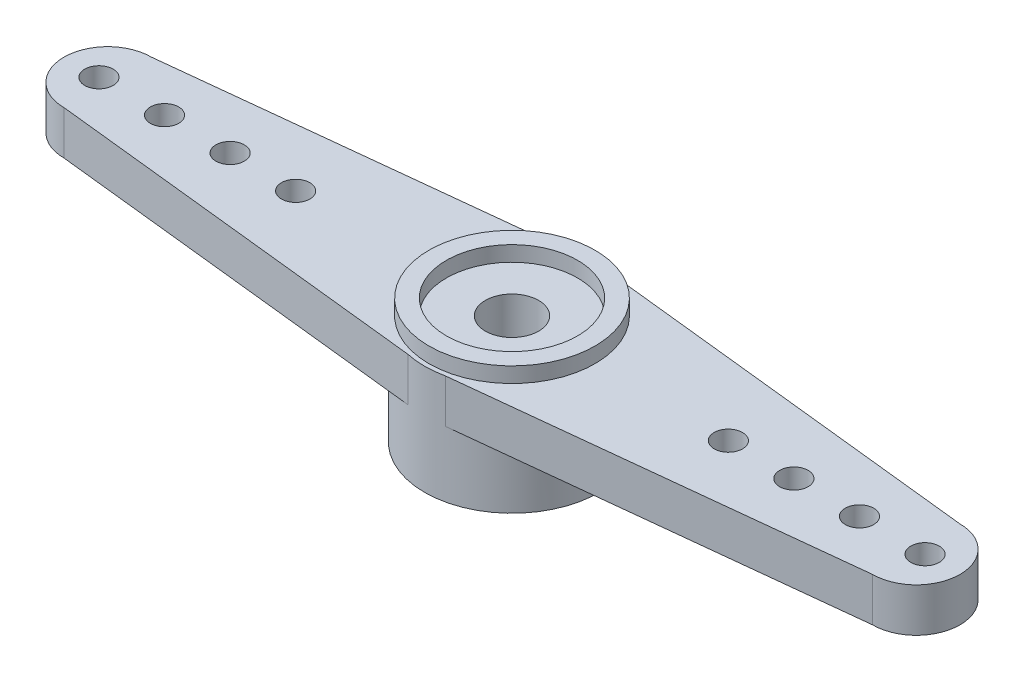
from build123d import *

# Parameters (mm, degrees)
SKETCH1_R      = 4
EXTRUDE1_DEPTH = 3
EXTRUDE3_DEPTH = 2
SKETCH3_R      = 0.65
EXTRUDE4_DEPTH = 2
SKETCH4_R      = 3.8
EXTRUDE5_DEPTH = 0.7
SKETCH5_R      = 3
EXTRUDE6_DEPTH = 1
SKETCH6_R      = 3
EXTRUDE7_DEPTH = 3.7
SKETCH7_R      = 1.219675703
EXTRUDE8_DEPTH = 40


with BuildPart() as part:
    # Sketch1 → Extrude1 (new body)
    with BuildSketch(Plane(origin=(0, 0, 0), x_dir=(1, 0, 0), z_dir=(0, 1, 0))):
        with Locations(Location((0, 0, 0), (0, 0, 270))):  # turned: the seam where the file's is
            Circle(SKETCH1_R)
    extrude(amount=EXTRUDE1_DEPTH)

    # Sketch2 → Extrude3 (add)
    with BuildSketch(Plane(origin=(0, 3, 0), x_dir=(1, 0, 0), z_dir=(0, 1, 0))):
        with BuildLine():
            Line((-0.854873646, 3.907581227), (-18.5, 2))
            ThreePointArc((-18.5, 2), (-20.5, 0), (-18.5, -2))
            Line((-18.5, -2), (-0.854873646, -3.907581227))
            ThreePointArc((-0.854873646, -3.907581227), (4, 0), (-0.854873646, 3.907581227))
        make_face()
    extrude3 = extrude(amount=EXTRUDE3_DEPTH)

    # Sketch3 → Extrude4 (cut)
    with BuildSketch(Plane(origin=(0, 5, 0), x_dir=(1, 0, 0), z_dir=(0, 1, 0))):
        with Locations(Location((-9.9, 0, 0), (0, 0, 270))):  # turned: the seam where the file's is
            Circle(SKETCH3_R)
        with Locations(Location((-12.9, 0, 0), (0, 0, 270))):  # turned: the seam where the file's is
            Circle(SKETCH3_R)
        with Locations(Location((-15.9, 0, 0), (0, 0, 270))):  # turned: the seam where the file's is
            Circle(SKETCH3_R)
        with Locations(Location((-18.9, 0, 0), (0, 0, 270))):  # turned: the seam where the file's is
            Circle(SKETCH3_R)
    extrude4 = extrude(amount=-EXTRUDE4_DEPTH, mode=Mode.SUBTRACT)

    # Sketch4 → Extrude5 (add)
    with BuildSketch(Plane(origin=(0, 5, 0), x_dir=(-1, 0, 0), z_dir=(0, 1, 0))):
        with Locations(Location((0, 0, 0), (0, 0, 90))):  # turned: the seam where the file's is
            Circle(SKETCH4_R)
    extrude(amount=EXTRUDE5_DEPTH)

    # Sketch5 → Extrude6 (cut)
    with BuildSketch(Plane(origin=(0, 5.7, 0), x_dir=(1, 0, 0), z_dir=(0, 1, 0))):
        with Locations(Location((0, 0, 0), (0, 0, 270))):  # turned: the seam where the file's is
            Circle(SKETCH5_R)
    extrude(amount=-EXTRUDE6_DEPTH, mode=Mode.SUBTRACT)

    # Sketch6 → Extrude7 (cut)
    with BuildSketch(Plane.XZ):
        with Locations(Location((0, 0, 0), (0, 0, 90))):  # turned: the seam where the file's is
            Circle(SKETCH6_R)
    extrude(amount=-EXTRUDE7_DEPTH, mode=Mode.SUBTRACT)

    # Mirror1: Extrude3, Extrude4 across plane
    add(extrude3.mirror(Plane(origin=(0, 0, 0), x_dir=(0, 0, 1), z_dir=(1, 0, 0))))
    add(extrude4.mirror(Plane(origin=(0, 0, 0), x_dir=(0, 0, 1), z_dir=(1, 0, 0))), mode=Mode.SUBTRACT)

    # Sketch7 → Extrude8 (cut)
    with BuildSketch(Plane(origin=(0, 5, 0), x_dir=(1, 0, 0), z_dir=(0, 1, 0))):
        with Locations(Location((0, 0, 0), (0, 0, 270))):  # turned: the seam where the file's is
            Circle(SKETCH7_R)
    extrude(amount=-EXTRUDE8_DEPTH, mode=Mode.SUBTRACT)


solid = part.part
